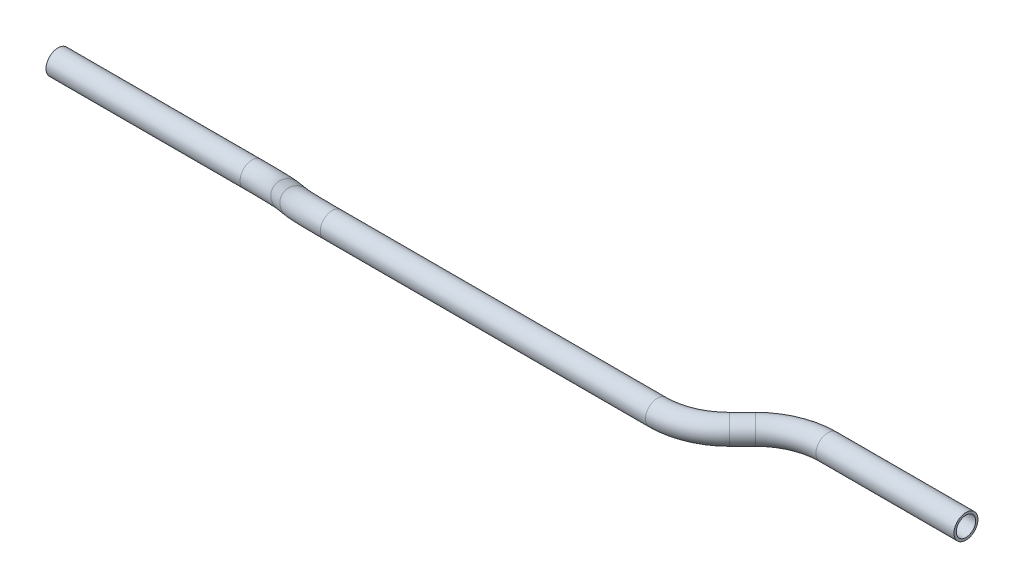
from build123d import *

# Parameters (mm, degrees)
SKETCH1_R   = 6.35
SKETCH1_R_2 = 5.1054


with BuildPart() as part:
    # Sweep2: sweep along a curve in space
    with BuildLine() as sweep2_path:
        Line((0, 0, 0), (102.457120878, 0, 0))
        ThreePointArc((102.457120878, 0, 0), (117.037359651, 1.978497966, 2.120529825), (129.397889241, 7.612783484, 8.159287858))
        Line((129.397889241, 7.612783484, 8.159287858), (147.029132583, 19.640747639, 21.050712142))
        ThreePointArc((147.029132583, 19.640747639, 21.050712142), (159.389662173, 25.275033157, 27.089470175), (173.969900946, 27.253531123, 29.21))
        Line((173.969900946, 27.253531123, 29.21), (345.606827493, 27.253531123, 29.21))
        ThreePointArc((345.606827493, 27.253531123, 29.21), (360.187066266, 27.253531123, 26.309810189), (372.547595856, 27.253531123, 18.050768363))
        Line((372.547595856, 27.253531123, 18.050768363), (379.439132583, 27.253531123, 11.159231637))
        ThreePointArc((379.439132583, 27.253531123, 11.159231637), (391.799662173, 27.253531123, 2.900189811), (406.379900946, 27.253531123, 0))
        Line((406.379900946, 27.253531123, 0), (479.251838424, 27.253531123, 0))
    # Sketch1 → Sweep2 (sweep)
    with BuildSketch(Plane(origin=(0, 0, 0), x_dir=(0, 0, -1), z_dir=(1, 0, 0))):
        Circle(SKETCH1_R)
        Circle(SKETCH1_R_2, mode=Mode.SUBTRACT)
    sweep(path=sweep2_path.line)


solid = part.part
